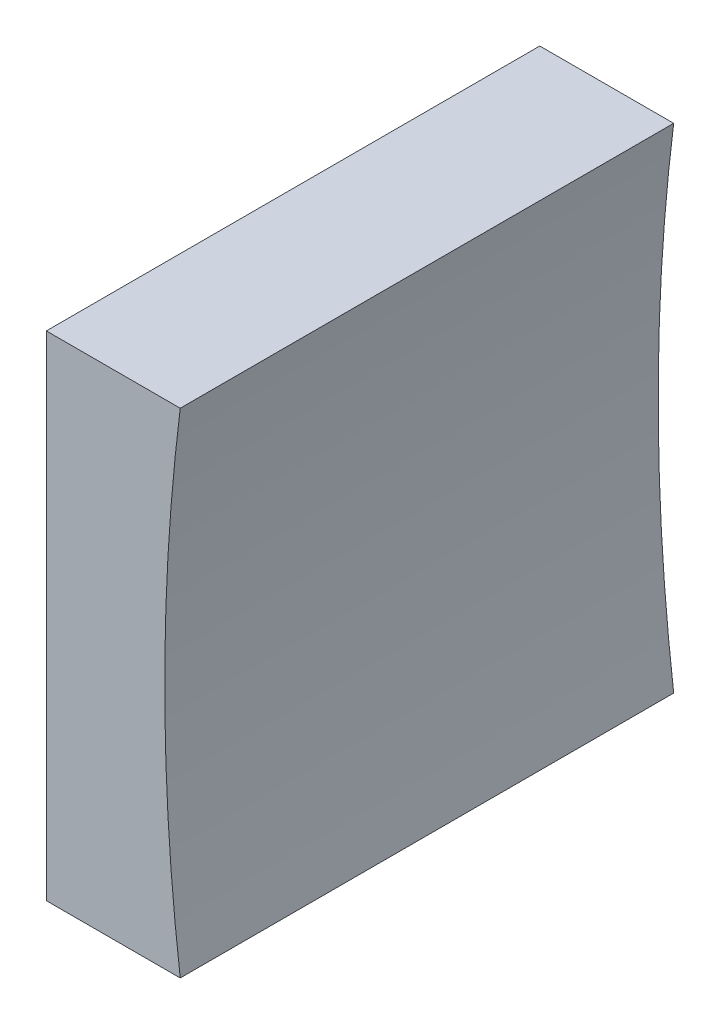
from build123d import *

# Parameters (mm, degrees)
EXTRUDE_1_DEPTH = 12.5


with BuildPart() as part:
    # 草图1 → 凸台-拉伸1 (new body)
    with BuildSketch(Plane.XY):
        with BuildLine():
            Line((142.353567816, 33.428964634), (142.353567816, 39.678964634))
            Line((142.353567816, 39.678964634), (145.745730748, 39.678964634))
            ThreePointArc((145.745730748, 39.678964634), (145.353567831, 33.428964634), (145.745730748, 27.178964634))
            Line((145.745730748, 27.178964634), (142.353567816, 27.178964634))
            Line((142.353567816, 27.178964634), (142.353567816, 33.428964634))
        make_face()
    extrude(amount=EXTRUDE_1_DEPTH)


solid = part.part
